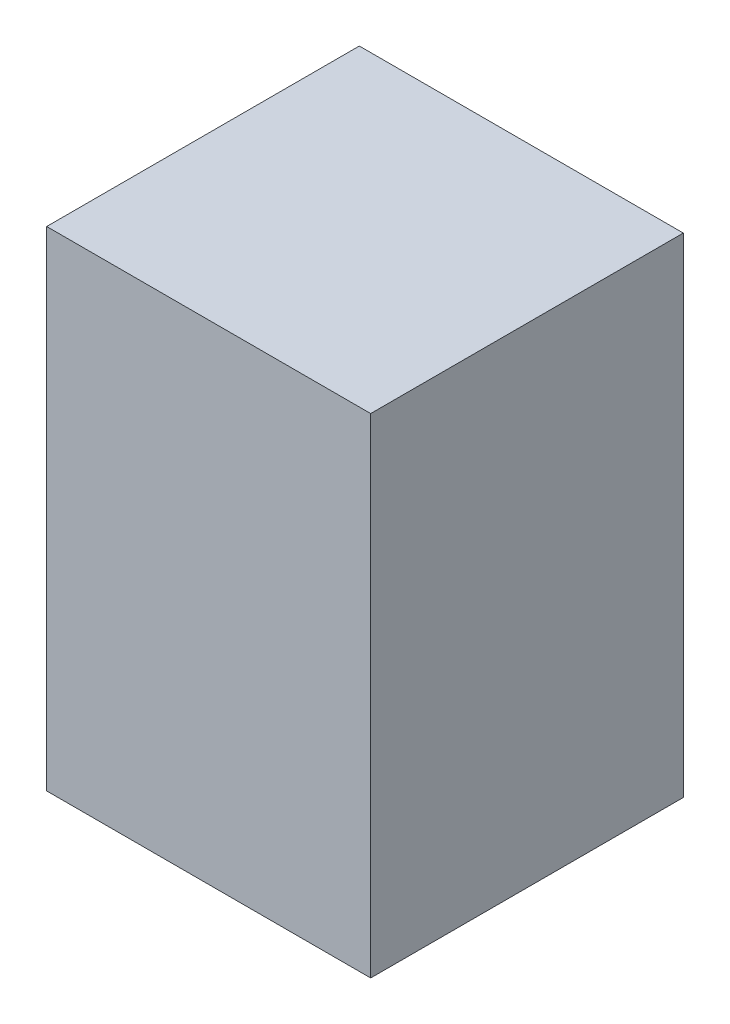
from build123d import *

# Parameters (mm, degrees)
SKETCH1_W           = 57
SKETCH1_H           = 86
BOSS_EXTRUDE1_DEPTH = 55
SKETCH7_R           = 0.5
CUT_EXTRUDE1_DEPTH  = 5


with BuildPart() as part:
    # Sketch1 → Boss-Extrude1 (new body)
    with BuildSketch(Plane.XY):
        with Locations((28.5, 43)):
            Rectangle(SKETCH1_W, SKETCH1_H)
    extrude(amount=BOSS_EXTRUDE1_DEPTH)

    # Sketch7 → Cut-Extrude1 (cut)
    with BuildSketch(Plane(origin=(0, 0, 0), x_dir=(-1, 0, 0), z_dir=(0, 0, -1))):
        with Locations((-4, 1.5)):
            Circle(SKETCH7_R)
        with Locations((-53, 1.5)):
            Circle(SKETCH7_R)
        with Locations((-4, 84.5)):
            Circle(SKETCH7_R)
        with Locations((-53, 84.5)):
            Circle(SKETCH7_R)
    extrude(amount=-CUT_EXTRUDE1_DEPTH, mode=Mode.SUBTRACT)


solid = part.part
